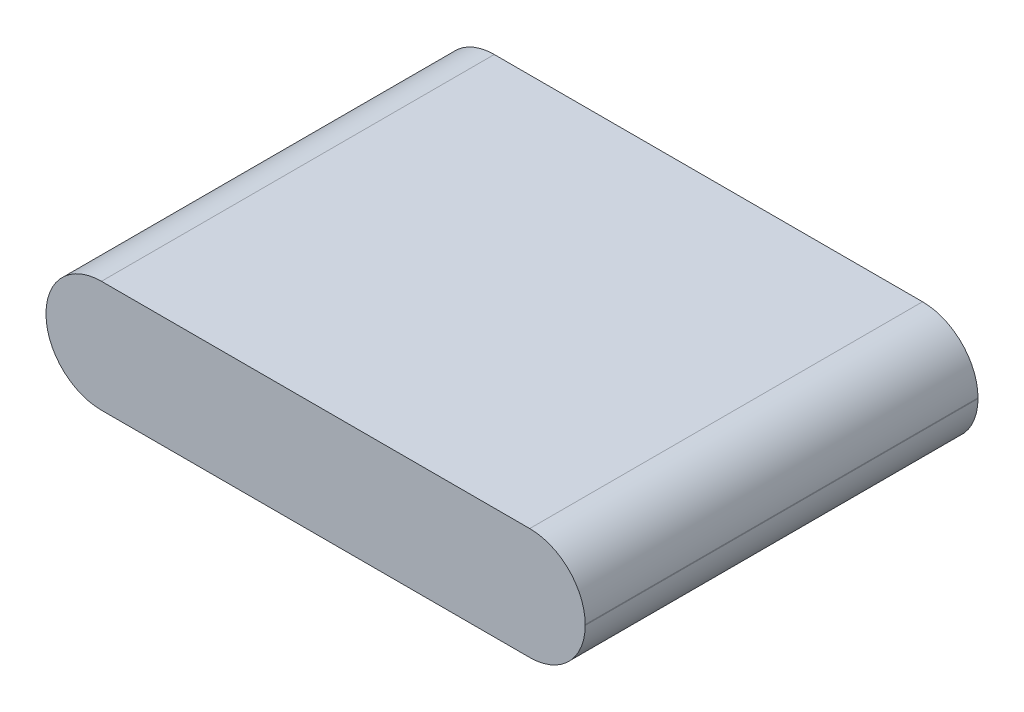
from build123d import *

# Parameters (mm, degrees)
SKETCH1_W           = 70
SKETCH1_H           = 51
BOSS_EXTRUDE1_DEPTH = 14.5
FILLET1_R           = 7.2


with BuildPart() as part:
    # Sketch1 → Boss-Extrude1 (new body)
    with BuildSketch(Plane(origin=(0, 0, 0), x_dir=(1, 0, 0), z_dir=(0, 1, 0))):
        Rectangle(SKETCH1_W, SKETCH1_H)
    extrude(amount=BOSS_EXTRUDE1_DEPTH)

    # Fillet1
    fillet1_edges = [part.edges().sort_by_distance(p)[0] for p in [
        (-35, 14.5, 0),
        (35, 14.5, 0),
        (-35, 0, 0),
        (35, 0, 0),
    ]]
    fillet(fillet1_edges, radius=FILLET1_R)


solid = part.part
